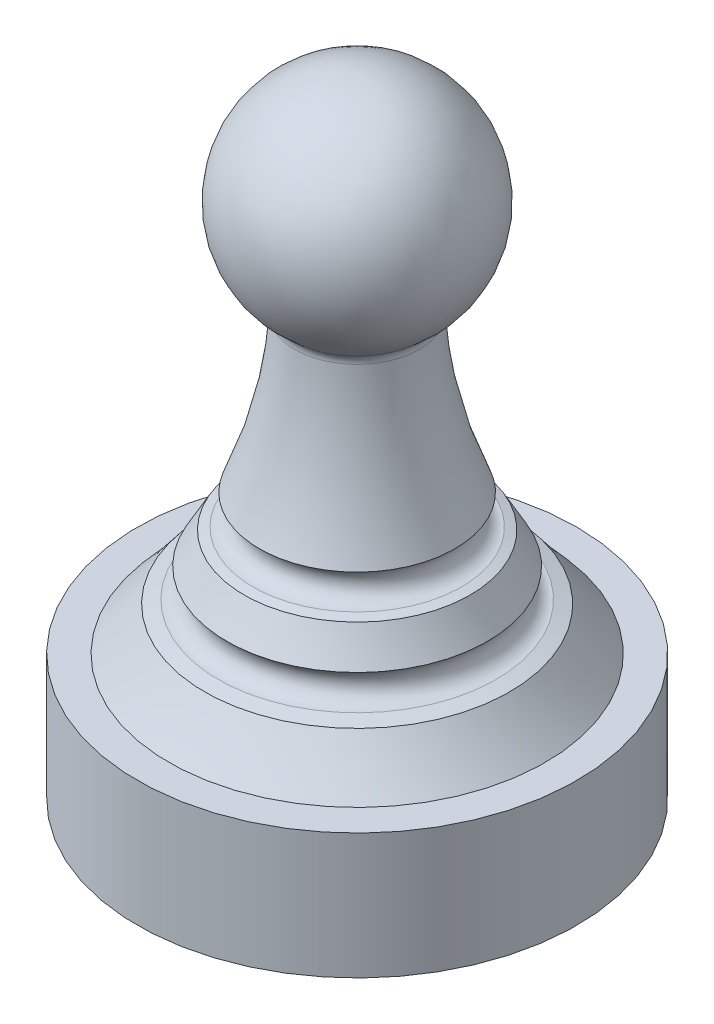
from build123d import *

# Parameters (mm, degrees)
SKETCH3_R           = 7
BOSS_EXTRUDE1_DEPTH = 2
BOSS_EXTRUDE2_START = -2
SKETCH3_3_R         = 7
BOSS_EXTRUDE2_DEPTH = 2
SKETCH5_R           = 6.05
CUT_EXTRUDE1_DEPTH  = 3.2


with BuildPart() as part:
    # Esboço1 → Revolução1 (revolve)
    with BuildSketch(Plane.XY):
        with BuildLine():
            Line((-6, 0), (0, 0))
            Line((0, 0), (0, 18))
            ThreePointArc((0, 18), (-3.312799908, 15.629316948), (-2.13782919, 11.728775297))
            ThreePointArc((-2.13782919, 11.728775297), (-2.018299709, 11.578229866), (-1.98280027, 11.389309212))
            ThreePointArc((-1.98280027, 11.389309212), (-2.341324967, 8.875429394), (-3.118754256, 6.458047463))
            ThreePointArc((-3.118754256, 6.458047463), (-2.829835487, 5.897588408), (-3.319234982, 5.5))
            Line((-3.319234982, 5.5), (-3.6002073, 5.419432484))
            ThreePointArc((-3.6002073, 5.419432484), (-3.869815727, 4.915531149), (-4.158423427, 4.422265648))
            ThreePointArc((-4.158423427, 4.422265648), (-3.946003212, 3.860595596), (-4.426176527, 3.5))
            Line((-4.426176527, 3.5), (-4.85988246, 3.375636825))
            ThreePointArc((-4.85988246, 3.375636825), (-5.409441117, 2.670828072), (-6, 2))
            Line((-6, 2), (-6, 0))
        make_face()
    revolve(axis=Axis((0, -3.799835873, 0), (0, 1, 0)))

    # Sketch3 → Boss-Extrude1 (add)
    with BuildSketch(Plane.XZ):
        Circle(SKETCH3_R)
    extrude(amount=BOSS_EXTRUDE1_DEPTH)

    # Sketch3_3 → Boss-Extrude2 (add)
    with BuildSketch(Plane.XZ.offset(BOSS_EXTRUDE2_START)):
        Circle(SKETCH3_3_R)
    extrude(amount=BOSS_EXTRUDE2_DEPTH)

    # Sketch5 → Cut-Extrude1 (cut)
    with BuildSketch(Plane.XZ.offset(2)):
        Circle(SKETCH5_R)
    extrude(amount=-CUT_EXTRUDE1_DEPTH, mode=Mode.SUBTRACT)


solid = part.part
